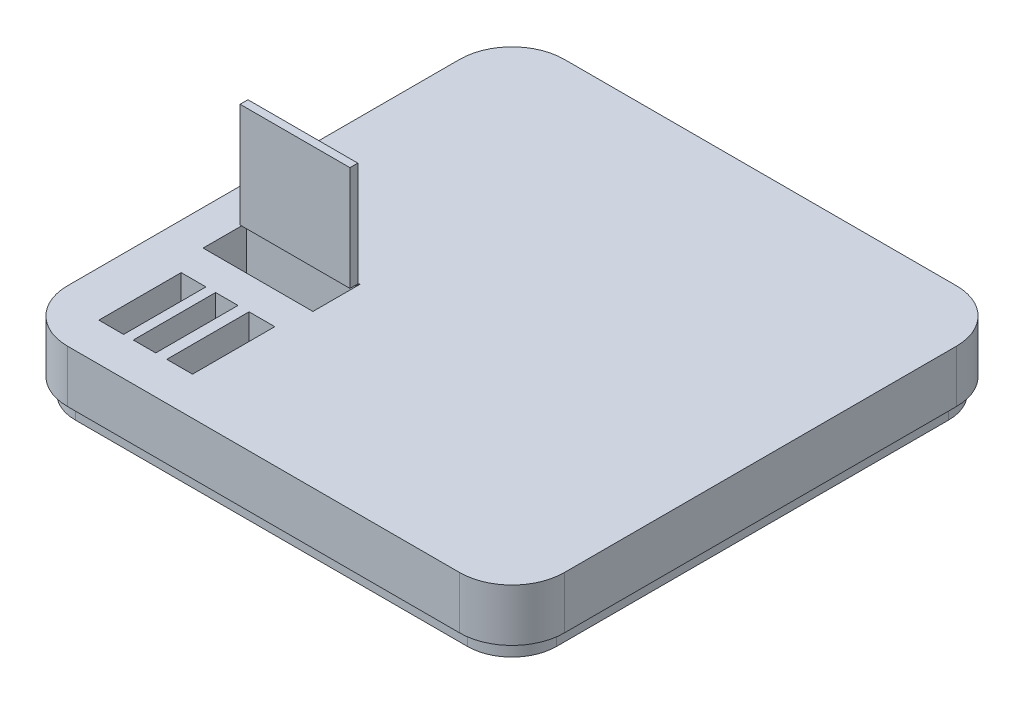
from build123d import *

# Parameters (mm, degrees)
SKETCH1_W            = 95
SKETCH1_H            = 95
BOSS_EXTRUDE1_DEPTH  = 10
FILLET1_R            = 10
BOSS_EXTRUDE2_DEPTH  = 3
SKETCH5_W            = 4.733468523
SKETCH5_H            = 15.739624206
SKETCH5_W_2          = 4.285968544
SKETCH5_W_3          = 4.922499766
CUT_EXTRUDE1_DEPTH   = 10
SKETCH14_W           = 21
SKETCH14_H           = 9
CUT_EXTRUDE2_DEPTH   = 10
SKETCH16_W           = 21.335954762
SKETCH16_H           = 13.618694529
BOSS_EXTRUDE7_DEPTH  = 10
SKETCH20_W           = 21
SKETCH20_H           = 1.5
BOSS_EXTRUDE13_DEPTH = 20


with BuildPart() as part:
    # Sketch1 → Boss-Extrude1 (new body)
    with BuildSketch(Plane(origin=(-45.242822535, 0, -5.598622024), x_dir=(1, 0, 0), z_dir=(0, 1, 0))):
        Rectangle(SKETCH1_W, SKETCH1_H)
    extrude(amount=BOSS_EXTRUDE1_DEPTH)

    # Fillet1
    fillet1_edges = [part.edges().sort_by_distance(p)[0] for p in [
        (2.257177465, 5, 41.901377976),
        (-92.742822535, 5, 41.901377976),
        (-92.742822535, 5, -53.098622024),
        (2.257177465, 5, -53.098622024),
    ]]
    fillet(fillet1_edges, radius=FILLET1_R)

    # Sketch4 → Boss-Extrude2 (add)
    with BuildSketch(Plane(origin=(-45.242822535, 0, -5.598622024), x_dir=(1, 0, 0), z_dir=(0, -1, 0))):
        with BuildLine():
            Line((-46, 37.5), (-46, -37.5))
            ThreePointArc((-46, -37.5), (-43.51040764, -43.51040764), (-37.5, -46))
            Line((-37.5, -46), (37.5, -46))
            ThreePointArc((37.5, -46), (43.51040764, -43.51040764), (46, -37.5))
            Line((46, -37.5), (46, 37.5))
            ThreePointArc((46, 37.5), (43.51040764, 43.51040764), (37.5, 46))
            Line((37.5, 46), (-37.5, 46))
            ThreePointArc((-37.5, 46), (-43.51040764, 43.51040764), (-46, 37.5))
        make_face()
    extrude(amount=BOSS_EXTRUDE2_DEPTH)

    # Sketch5 → Cut-Extrude1 (cut)
    with BuildSketch(Plane(origin=(-45.242822535, 10, -5.598622024), x_dir=(1, 0, 0), z_dir=(0, 1, 0))):
        with Locations((-36.445515764, -32.326942183)):
            Rectangle(SKETCH5_W, SKETCH5_H)
        with Locations((-30.082156711, -32.326942183)):
            Rectangle(SKETCH5_W_2, SKETCH5_H)
        with Locations((-23.365813302, -32.326942183)):
            Rectangle(SKETCH5_W_3, SKETCH5_H)
    extrude(amount=-CUT_EXTRUDE1_DEPTH, mode=Mode.SUBTRACT)

    # Sketch14 → Cut-Extrude2 (cut)
    with BuildSketch(Plane(origin=(0, 10, 0), x_dir=(1, 0, 0), z_dir=(0, 1, 0))):
        with Locations((-75.521903194, -8.192829138)):
            Rectangle(SKETCH14_W, SKETCH14_H)
    extrude(amount=-CUT_EXTRUDE2_DEPTH, mode=Mode.SUBTRACT)

    # Sketch16 → Boss-Extrude7 (add)
    with BuildSketch(Plane(origin=(0, 0, 0), x_dir=(1, 0, 0), z_dir=(0, 1, 0))):
        with Locations((-75.859791542, 2.420926633)):
            Rectangle(SKETCH16_W, SKETCH16_H)
    extrude(amount=BOSS_EXTRUDE7_DEPTH)

    # Sketch20 → Boss-Extrude13 (add)
    with BuildSketch(Plane(origin=(0, 10, 0), x_dir=(1, 0, 0), z_dir=(0, 1, 0))):
        with Locations((-75.800790681, -4.586951107)):
            Rectangle(SKETCH20_W, SKETCH20_H)
    extrude(amount=BOSS_EXTRUDE13_DEPTH)


solid = part.part
